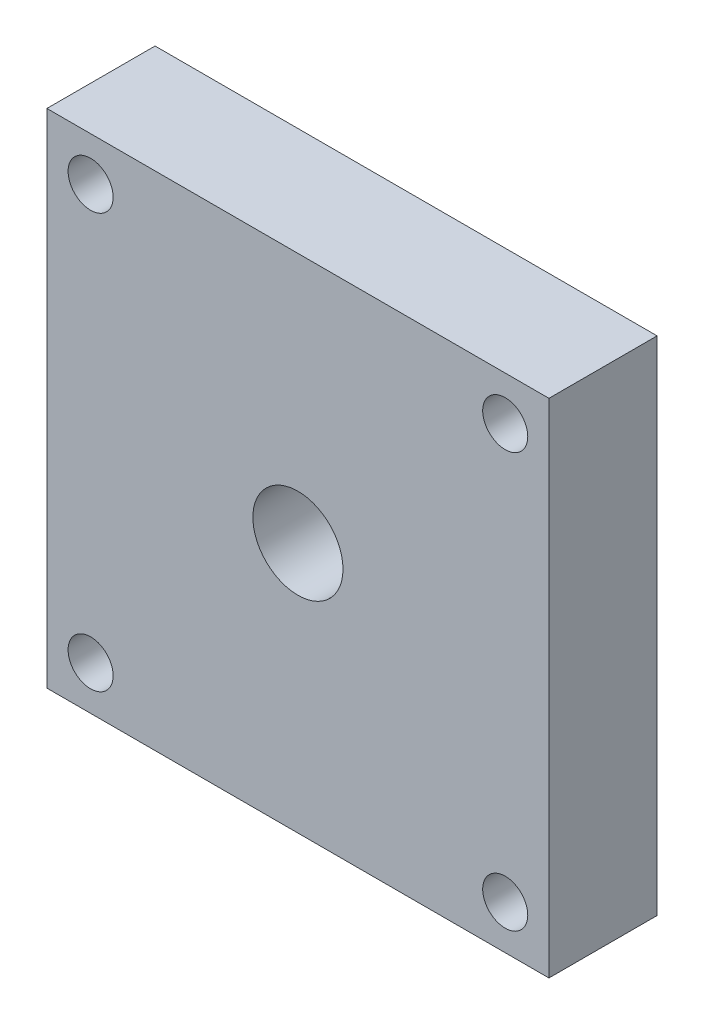
from build123d import *

# Parameters (mm, degrees)
ESQUISSE1_W        = 27.85
ESQUISSE1_H        = 27.85
ESQUISSE1_R        = 1.25
ESQUISSE1_R_2      = 2.5
BOSS_EXTRU_1_DEPTH = 6


with BuildPart() as part:
    # Esquisse1 → Boss.-Extru.1 (new body)
    with BuildSketch(Plane.XY):
        with Locations((1.035743802, -2.301652893)):
            Rectangle(ESQUISSE1_W, ESQUISSE1_H)
        with Locations((12.535743802, 9.193347107)):
            Circle(ESQUISSE1_R, mode=Mode.SUBTRACT)
        with Locations((-10.464256198, 9.193347107)):
            Circle(ESQUISSE1_R, mode=Mode.SUBTRACT)
        with Locations((-10.464256198, -13.796652893)):
            Circle(ESQUISSE1_R, mode=Mode.SUBTRACT)
        with Locations((12.535743802, -13.796652893)):
            Circle(ESQUISSE1_R, mode=Mode.SUBTRACT)
        with Locations((1.035743802, -2.301652893)):
            Circle(ESQUISSE1_R_2, mode=Mode.SUBTRACT)
    extrude(amount=BOSS_EXTRU_1_DEPTH)


solid = part.part
